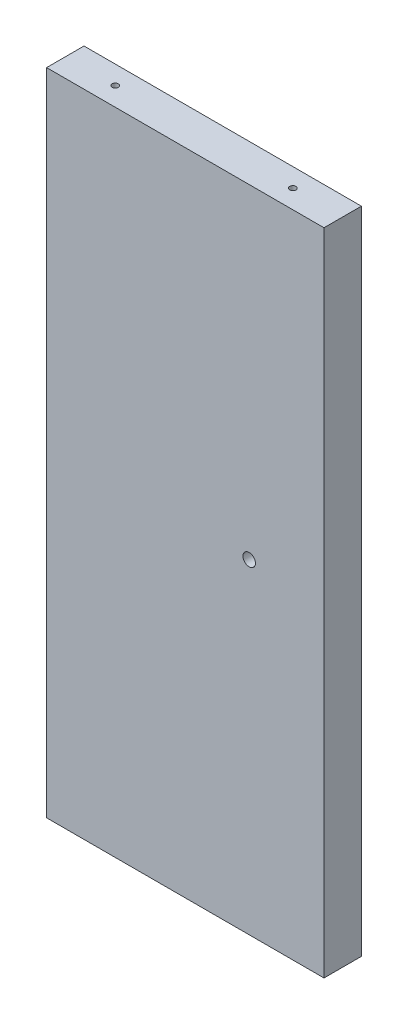
from build123d import *

# Parameters (mm, degrees)
SKETCH1_W                   = 141.287862113
SKETCH1_H                   = 330.949999988
BOSS_EXTRUDE1_DEPTH         = 19.05
HOLE1_D                     = 3.175
HOLE1_DEPTH                 = 31.75
HOLE1_CSINK_D               = 10.16
HOLE1_CSINK_ANGLE           = 82
HOLE1_TIP                   = 0.953866233
HOLE3_D                     = 3.175
HOLE3_DEPTH                 = 38.1
HOLE3_CSINK_D               = 10.16
HOLE3_CSINK_ANGLE           = 82
HOLE3_TIP                   = 0.953866233
F_1_4_0_25_DIAMETER_HOLE1_D = 6.35
HOLE4_D                     = 3.175
HOLE4_DEPTH                 = 31.75
HOLE4_CSINK_D               = 10.16
HOLE4_CSINK_ANGLE           = 82
HOLE4_TIP                   = 0.953866233
HOLE5_D                     = 3.175
HOLE5_DEPTH                 = 38.1
HOLE5_CSINK_D               = 10.16
HOLE5_CSINK_ANGLE           = 82
HOLE5_TIP                   = 0.953866233


with BuildPart() as part:
    # Sketch1 → Boss-Extrude1 (new body)
    with BuildSketch(Plane.XY):
        with Locations((279.996898238, -72.024999997)):
            Rectangle(SKETCH1_W, SKETCH1_H)
    extrude(amount=BOSS_EXTRUDE1_DEPTH)

    # Hole1
    with Locations(Plane(origin=(196.652967181, -72.024999997, 386.262770337), x_dir=(0, 1, 0), z_dir=(-1, 0, 0))):
        with Locations((174.999999994, 685.961004241), (174.999999994, 549.837259632), (174.999999994, 413.713515022), (81.549999997, 779.649723129), (81.549999997, 652.344645962), (62.499999997, 662.953402392), (62.499999997, 769.040966698), (-62.499999997, 769.040966698), (-62.499999997, 662.953402392), (-81.549999997, 652.344645962), (-81.549999997, 779.649723129), (-174.999999994, 413.713515022), (-174.999999994, 549.837259632), (-174.999999994, 685.961004241), (-82.737499997, 600.384620239), (0, 600.384620239), (82.737499997, 600.384620239), (0, 376.737770337), (-82.737499997, 376.737770337), (82.737499997, 376.737770337)):
            CounterSinkHole(HOLE1_D / 2, HOLE1_CSINK_D / 2, depth=HOLE1_DEPTH, counter_sink_angle=HOLE1_CSINK_ANGLE)
            with Locations((0, 0, -(HOLE1_DEPTH + HOLE1_TIP / 2))):  # 118° drill point
                Cone(0, HOLE1_D / 2, HOLE1_TIP, mode=Mode.SUBTRACT)

    # Hole3
    with Locations(Plane(origin=(-181.039434513, 112.499999997, 386.262770337), x_dir=(0.927183855, 0, -0.374606593), z_dir=(0, 1, 0))):
        with Locations((46.221112845, 113.488854888), (39.39759596, 37.945520226), (412.28786892, 80.423559293), (407.308516105, 25.297013484), (513.561319184, 161.164706775), (597.46020397, 127.267357003), (610.543339245, 159.649253123), (694.322923815, 367.011001477), (526.644454459, 193.546602895), (610.424039029, 400.908351249)):
            CounterSinkHole(HOLE3_D / 2, HOLE3_CSINK_D / 2, depth=HOLE3_DEPTH, counter_sink_angle=HOLE3_CSINK_ANGLE)
            with Locations((0, 0, -(HOLE3_DEPTH + HOLE3_TIP / 2))):  # 118° drill point
                Cone(0, HOLE3_D / 2, HOLE3_TIP, mode=Mode.SUBTRACT)

    # 1/4 (0.25) Diameter Hole1 (through all)
    with Locations(Plane(origin=(0, 0, 0), x_dir=(-1, 0, 0), z_dir=(0, 0, -1))):
        with Locations((-312.540829294, -72.024999997)):
            Hole(F_1_4_0_25_DIAMETER_HOLE1_D / 2)

    # Hole4
    with Locations(Plane(origin=(196.652967181, -72.024999997, 609.909620239), x_dir=(0, 1, 0), z_dir=(-1, 0, 0))):
        with Locations((174.999999994, 685.961004241), (174.999999994, 549.837259632), (174.999999994, 413.713515022), (81.549999997, 779.649723129), (81.549999997, 652.344645962), (62.499999997, 662.953402392), (62.499999997, 769.040966698), (-62.499999997, 769.040966698), (-62.499999997, 662.953402392), (-81.549999997, 652.344645962), (-81.549999997, 779.649723129), (-174.999999994, 413.713515022), (-174.999999994, 549.837259632), (-174.999999994, 685.961004241), (-82.737499997, 600.384620239), (0, 600.384620239), (82.737499997, 600.384620239), (0, 376.737770337), (-82.737499997, 376.737770337), (82.737499997, 376.737770337)):
            CounterSinkHole(HOLE4_D / 2, HOLE4_CSINK_D / 2, depth=HOLE4_DEPTH, counter_sink_angle=HOLE4_CSINK_ANGLE)
            with Locations((0, 0, -(HOLE4_DEPTH + HOLE4_TIP / 2))):  # 118° drill point
                Cone(0, HOLE4_D / 2, HOLE4_TIP, mode=Mode.SUBTRACT)

    # Hole5
    with Locations(Plane(origin=(-181.039434513, 112.499999997, 609.909620239), x_dir=(0.927183855, 0, -0.374606593), z_dir=(0, 1, 0))):
        with Locations((46.221112845, 113.488854888), (39.39759596, 37.945520226), (412.28786892, 80.423559293), (407.308516105, 25.297013484), (513.561319184, 161.164706775), (597.46020397, 127.267357003), (610.543339245, 159.649253123), (694.322923815, 367.011001477), (526.644454459, 193.546602895), (610.424039029, 400.908351249)):
            CounterSinkHole(HOLE5_D / 2, HOLE5_CSINK_D / 2, depth=HOLE5_DEPTH, counter_sink_angle=HOLE5_CSINK_ANGLE)
            with Locations((0, 0, -(HOLE5_DEPTH + HOLE5_TIP / 2))):  # 118° drill point
                Cone(0, HOLE5_D / 2, HOLE5_TIP, mode=Mode.SUBTRACT)


solid = part.part
